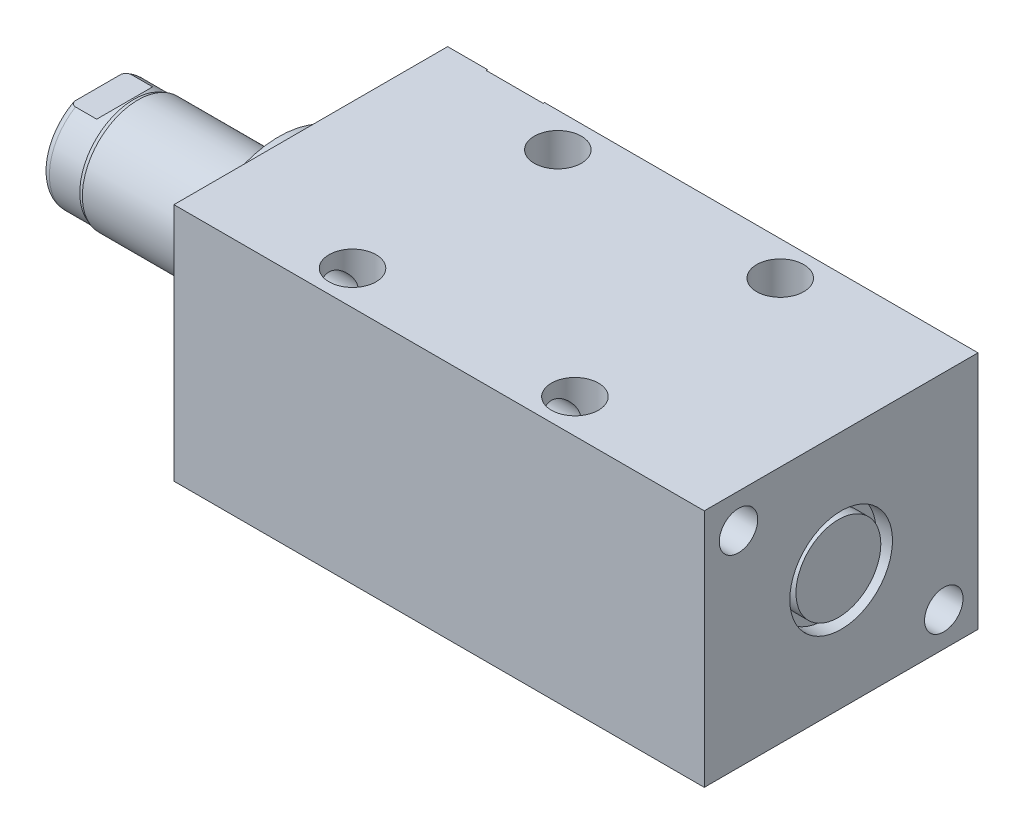
from build123d import *

# Parameters (mm, degrees)
SKETCH1_W          = 50.8
SKETCH1_H          = 44.45
EXTRUDE1_DEPTH     = 98.425
SKETCH5_R          = 17.4625
EXTRUDE2_DEPTH     = 5.969
SKETCH6_W          = 10.31875
SKETCH6_H          = 33.528
CUT_EXTRUDE4_DEPTH = 30.48
SKETCH13_R         = 7.874
EXTRUDE3_DEPTH     = 2.54
HOLE1_D            = 7.1374
HOLE1_DEPTH        = 98.425
HOLE2_D            = 8.7376
HOLE2_DEPTH        = 44.45
LPATTERN1_COUNT    = 2
LPATTERN1_PITCH    = 41.275
SKETCH18_R         = 7.874
EXTRUDE4_DEPTH     = 2.54


with BuildPart() as part:
    # Sketch1 → Extrude1 (new body)
    with BuildSketch(Plane(origin=(0, 0, 0), x_dir=(0, 0, -1), z_dir=(1, 0, 0))):
        Rectangle(SKETCH1_W, SKETCH1_H)
    extrude(amount=EXTRUDE1_DEPTH)

    # S2D0002 → Cut-Revolve1 (revolve, cut)
    with BuildSketch(Plane(origin=(0, 14.3002, 0), x_dir=(-1, 0, 0), z_dir=(0, 1, 0)), mode=Mode.PRIVATE) as cut_revolve1_sk:
        Polygon((-18.8849, -25.146), (-22.225, -25.146), (-22.225, -25.4), (-12.7, -25.4), (-12.7, -11.176), (-17.6784, -11.176), (-17.6784, -21.929393135), (-18.342306865, -22.5933), align=None)
    revolve(cut_revolve1_sk.sketch.rotate(Axis((12.7, 14.3002, -19.13842003), (0, 0, 1)), 180), axis=Axis((12.7, 14.3002, -19.13842003), (0, 0, 1)), mode=Mode.SUBTRACT)  # turned: the seam where the file's is

    # Sketch3 → Cut-Revolve2 (revolve, cut)
    with BuildSketch(Plane(origin=(41.148, 0, -25.146), x_dir=(1, 0, 0), z_dir=(0, 1, 0))):
        Polygon((47.5869, 0), (50.927, 0), (50.927, 0.254), (41.402, 0.254), (41.402, -13.97), (46.3804, -13.97), (46.3804, -3.216606865), (47.044306865, -2.5527), align=None)
    revolve(axis=Axis((82.55, 0, -3.189624441), (0, 0, -1)), mode=Mode.SUBTRACT)

    # Sketch4 → Cut-Revolve3 (revolve, cut)
    with BuildSketch(Plane(origin=(53.975, 0, 0), x_dir=(0, -1, 0), z_dir=(0, 0, 1)), mode=Mode.PRIVATE) as cut_revolve3_sk:
        Polygon((6.1849, 41.402), (9.525, 41.402), (9.525, 44.45), (0, 44.45), (0, 30.0482), (4.9784, 30.0482), (4.9784, 38.185393135), (5.642306865, 38.8493), align=None)
    revolve(cut_revolve3_sk.sketch.rotate(Axis((38.879609832, 0, 0), (1, 0, 0)), 270), axis=Axis((38.879609832, 0, 0), (1, 0, 0)), mode=Mode.SUBTRACT)  # turned: the seam where the file's is

    # Sketch5 → Extrude2 (add)
    with BuildSketch(Plane.ZY):
        Circle(SKETCH5_R)
    extrude(amount=EXTRUDE2_DEPTH)

    # Sketch6 → Revolve1 (revolve)
    with BuildSketch(Plane(origin=(0, 0, 0), x_dir=(0, 0, 1), z_dir=(0, -1, 0)), mode=Mode.PRIVATE) as revolve1_sk:
        with Locations((-5.159375, 22.733)):
            Rectangle(SKETCH6_W, SKETCH6_H)
    revolve(revolve1_sk.sketch.rotate(Axis((5.754582971, 0, 0), (-1, 0, 0)), 180), axis=Axis((5.754582971, 0, 0), (-1, 0, 0)))  # turned: the seam where the file's is

    # S2D0001 → Cut-Revolve4 (revolve, cut)
    with BuildSketch(Plane(origin=(-18.511260017, 3.2639, 0), x_dir=(0, 1, 0), z_dir=(0, 0, 1)), mode=Mode.PRIVATE) as cut_revolve4_sk:
        Polygon((0, 19.05), (0, 5.923539983), (-3.2639, 5.923539983), (-3.2639, 20.985739983), (1.1176, 20.985739983), align=None)
    revolve(cut_revolve4_sk.sketch.rotate(Axis((0, 0, 0), (-1, 0, 0)), 270), axis=Axis((0, 0, 0), (-1, 0, 0)), mode=Mode.SUBTRACT)  # turned: the seam where the file's is

    # Sketch8 → Cut-Revolve5 (revolve, cut)
    with BuildSketch(Plane(origin=(0, 0, 0), x_dir=(0, 0, -1), z_dir=(0, 1, 0)), mode=Mode.PRIVATE) as cut_revolve5_sk:
        with BuildLine():
            Line((-10.31875, 32.0802), (-10.033, 32.8422))
            Line((-10.033, 32.8422), (-10.033, 38.481))
            ThreePointArc((-10.033, 38.481), (-9.932678675, 39.024796865), (-9.644922533, 39.497))
            Line((-9.644922533, 39.497), (-10.31875, 39.497))
            Line((-10.31875, 39.497), (-10.31875, 32.0802))
        make_face()
    revolve(cut_revolve5_sk.sketch.rotate(Axis((-12.65936, 0, 0), (-1, 0, 0)), 180), axis=Axis((-12.65936, 0, 0), (-1, 0, 0)), mode=Mode.SUBTRACT)  # turned: the seam where the file's is

    # Sketch12 → Cut-Extrude4 (cut, symmetric)
    with BuildSketch(Plane(origin=(0, 0, 0), x_dir=(0, -1, 0), z_dir=(0, 0, -1))):
        Polygon((8.5852, 39.497), (8.5852, 34.544), (10.033, 33.0962), (10.033, 39.497), align=None)
        Polygon((-8.5852, 39.497), (-8.5852, 34.544), (-10.033, 33.0962), (-10.033, 39.497), align=None)
    extrude(amount=CUT_EXTRUDE4_DEPTH, both=True, mode=Mode.SUBTRACT)

    # Sketch13 → Extrude3 (add)
    with BuildSketch(Plane(origin=(0, 0, -25.146), x_dir=(-1, 0, 0), z_dir=(0, 0, -1))):
        with Locations(Location((-82.55, 0, 0), (0, 0, 180))):  # turned: the seam where the file's is
            Circle(SKETCH13_R)
    extrude(amount=EXTRUDE3_DEPTH)

    # Hole1
    with Locations(Plane.ZY):
        with Locations((-19.05, -15.875), (19.05, 15.875)):
            Hole(HOLE1_D / 2, depth=HOLE1_DEPTH)

    # Hole2
    with Locations(Plane(origin=(0, 22.225, 0), x_dir=(-1, 0, 0), z_dir=(0, 1, 0))):
        with Locations((-26.797, -19.05), (-26.797, 19.05)):
            hole2 = Hole(HOLE2_D / 2, depth=HOLE2_DEPTH)

    # LPattern1: Hole2 ×2
    with Locations(*[(i * LPATTERN1_PITCH, 0, 0) for i in range(1, LPATTERN1_COUNT)]):
        add(hole2, mode=Mode.SUBTRACT)

    # Sketch18 → Extrude4 (add)
    with BuildSketch(Plane(origin=(95.377, 0, 0), x_dir=(0, 0, -1), z_dir=(1, 0, 0))):
        with Locations(Location((0, 0, 0), (0, 0, 180))):  # turned: the seam where the file's is
            Circle(SKETCH18_R)
    extrude(amount=EXTRUDE4_DEPTH)


solid = part.part
